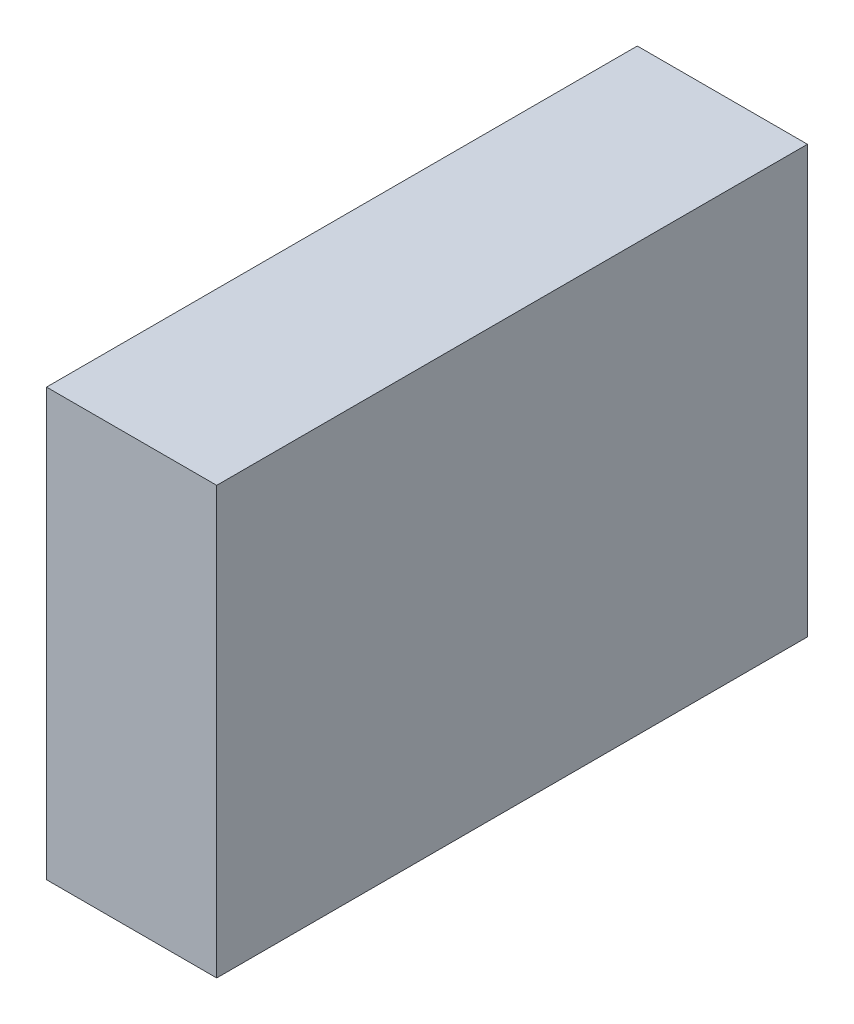
from build123d import *

# Parameters (mm, degrees)
SKETCH1_W           = 263.398
SKETCH1_H           = 660.4
BOSS_EXTRUDE1_DEPTH = 914.4


with BuildPart() as part:
    # Sketch1 → Boss-Extrude1 (new body)
    with BuildSketch(Plane.XY):
        with Locations((131.699, 330.2)):
            Rectangle(SKETCH1_W, SKETCH1_H)
    extrude(amount=BOSS_EXTRUDE1_DEPTH)


solid = part.part
